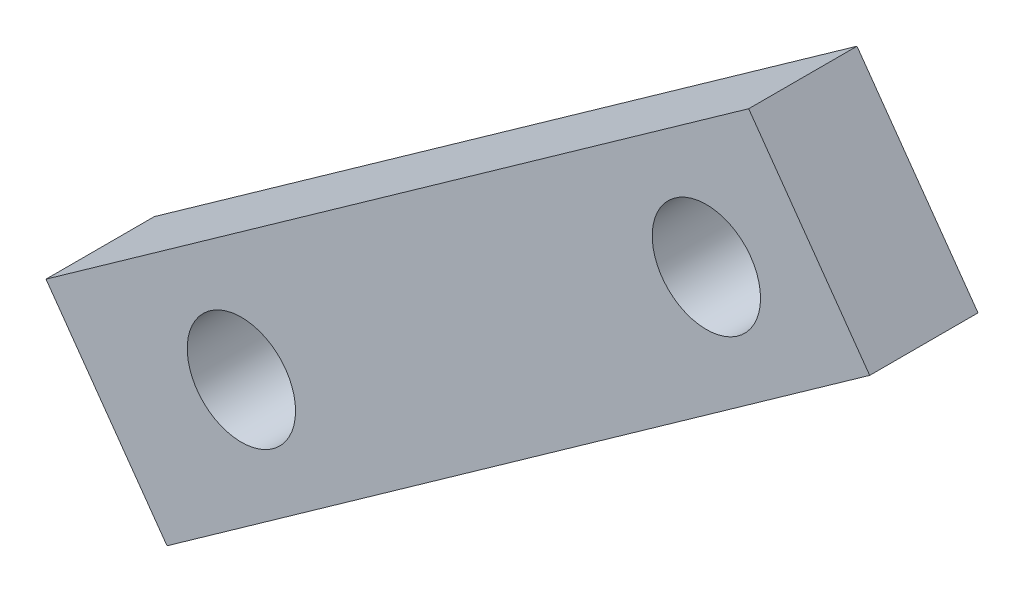
from build123d import *

# Parameters (mm, degrees)
BOSS_EXTRUDE1_DEPTH = 2.54


with BuildPart() as part:
    # Sketch1 → Boss-Extrude1 (new body)
    with BuildSketch(Plane.XY):
        with BuildLine():
            Line((-19.895895452, 5.257641235), (-22.301043484, 3.549986133))
            Line((-22.301043484, 3.549986133), (-21.620166741, 2.584921984))
            ThreePointArc((-21.620166741, 2.584921984), (-20.673812198, 2.799001601), (-19.852490319, 2.282428882))
            Line((-19.852490319, 2.282428882), (-18.476919787, 3.25908396))
            Line((-18.476919787, 3.25908396), (-19.895895452, 5.257641235))
        make_face()
        with BuildLine():
            Line((-17.057944121, 1.260526684), (-18.476919787, 3.25908396))
            Line((-18.476919787, 3.25908396), (-19.852490319, 2.282428882))
            ThreePointArc((-19.852490319, 2.282428882), (-19.678061583, 1.933053448), (-19.618026709, 1.547198045))
            ThreePointArc((-19.618026709, 1.547198045), (-19.76048118, 0.962782884), (-20.155886678, 0.509474105))
            Line((-20.155886678, 0.509474105), (-19.475009935, -0.455590043))
            Line((-19.475009935, -0.455590043), (-17.057944121, 1.260526684))
        make_face()
        with BuildLine():
            Line((-21.9235631, 0.811967207), (-30.756728475, -5.459580209))
            ThreePointArc((-30.756728475, -5.459580209), (-30.582299739, -5.808955643), (-30.522264866, -6.194811046))
            ThreePointArc((-30.522264866, -6.194811046), (-30.663849348, -6.77754462), (-31.057034029, -7.230347437))
            Line((-31.057034029, -7.230347437), (-30.3732892, -8.193368322))
            Line((-30.3732892, -8.193368322), (-19.475009935, -0.455590043))
            Line((-19.475009935, -0.455590043), (-20.155886678, 0.509474105))
            ThreePointArc((-20.155886678, 0.509474105), (-21.102241221, 0.295394489), (-21.9235631, 0.811967207))
        make_face()
        with BuildLine():
            Line((-22.301043484, 3.549986133), (-33.211240531, -4.196253771))
            Line((-33.211240531, -4.196253771), (-32.527495703, -5.159274656))
            ThreePointArc((-32.527495703, -5.159274656), (-31.579916773, -4.942689532), (-30.756728475, -5.459580209))
            Line((-30.756728475, -5.459580209), (-21.9235631, 0.811967207))
            ThreePointArc((-21.9235631, 0.811967207), (-22.139830266, 1.761412556), (-21.620166741, 2.584921984))
            Line((-21.620166741, 2.584921984), (-22.301043484, 3.549986133))
        make_face()
        with BuildLine():
            Line((-33.211240531, -4.196253771), (-36.374783749, -6.442369456))
            Line((-36.374783749, -6.442369456), (-34.955808084, -8.440926731))
            Line((-34.955808084, -8.440926731), (-32.827801256, -6.930041884))
            ThreePointArc((-32.827801256, -6.930041884), (-33.04438638, -5.982462953), (-32.527495703, -5.159274656))
            Line((-32.527495703, -5.159274656), (-33.211240531, -4.196253771))
        make_face()
        with BuildLine():
            Line((-32.827801256, -6.930041884), (-34.955808084, -8.440926731))
            Line((-34.955808084, -8.440926731), (-33.536832418, -10.439484007))
            Line((-33.536832418, -10.439484007), (-30.3732892, -8.193368322))
            Line((-30.3732892, -8.193368322), (-31.057034029, -7.230347437))
            ThreePointArc((-31.057034029, -7.230347437), (-32.004612959, -7.446932561), (-32.827801256, -6.930041884))
        make_face()
    extrude(amount=BOSS_EXTRUDE1_DEPTH)


solid = part.part
